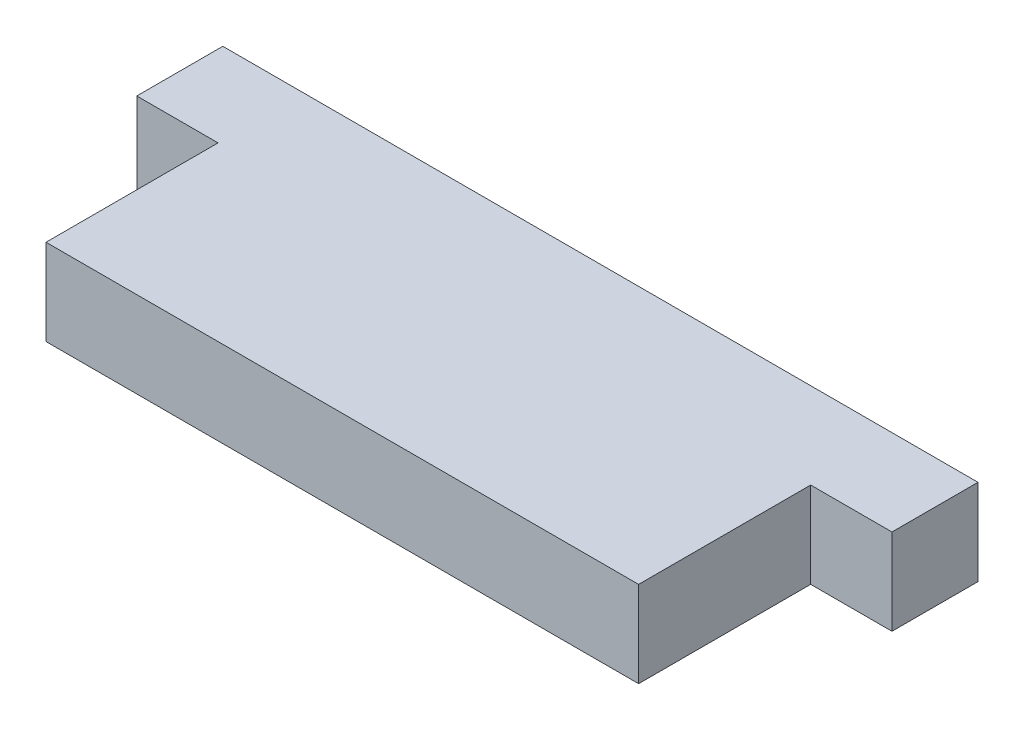
from build123d import *

# Parameters (mm, degrees)
BOSS_EXTRUDE1_DEPTH = 6.35


with BuildPart() as part:
    # Sketch1 → Boss-Extrude1 (new body)
    with BuildSketch(Plane(origin=(0, 0, 0), x_dir=(1, 0, 0), z_dir=(0, 1, 0))):
        Polygon((0, 0), (0, 12.7), (-5.999999938, 12.7), (-5.999999938, 19.05), (49.739999834, 19.05), (49.739999834, 12.7), (43.739999896, 12.7), (43.739999896, 0), align=None)
    extrude(amount=BOSS_EXTRUDE1_DEPTH)


solid = part.part
